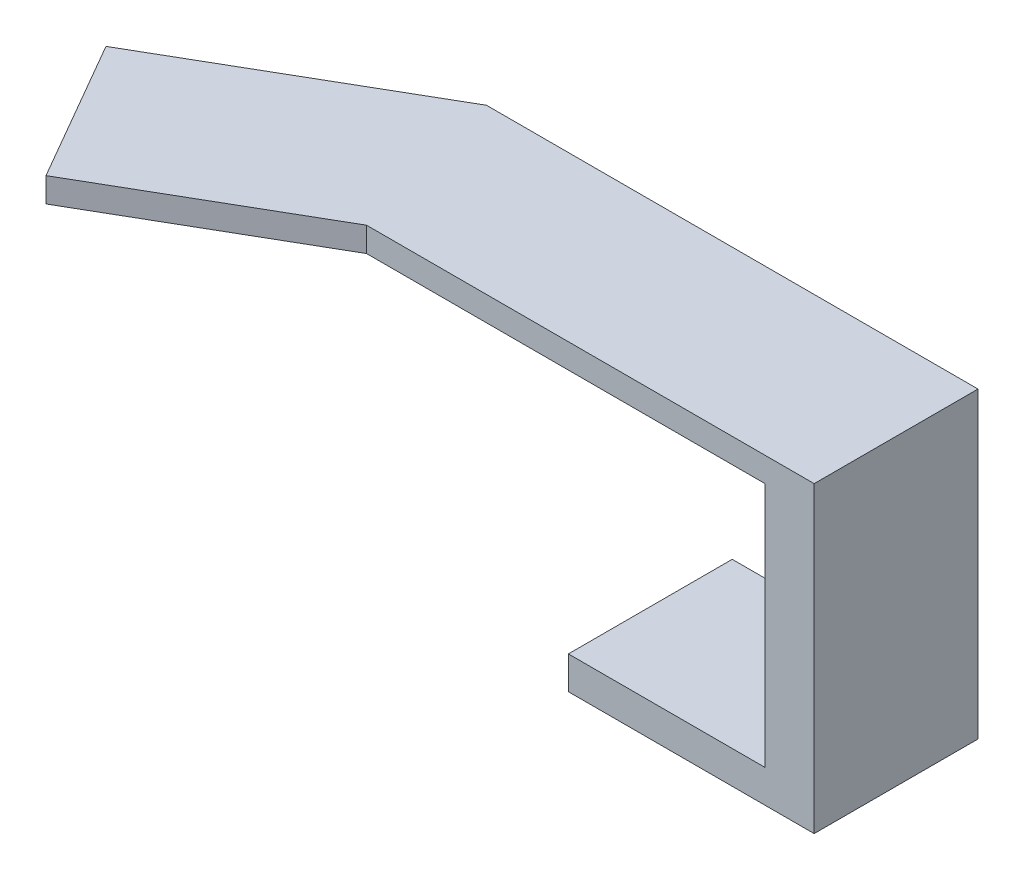
from build123d import *

# Parameters (mm, degrees)
BOSS_EXTRUDE1_DEPTH = 1.5
SKETCH2_W           = 3
SKETCH2_H           = 10
BOSS_EXTRUDE2_DEPTH = 17
SKETCH3_W           = 10
SKETCH3_H           = 2
BOSS_EXTRUDE3_DEPTH = 12


with BuildPart() as part:
    # Sketch1 → Boss-Extrude1 (new body)
    with BuildSketch(Plane(origin=(0, 0, 0), x_dir=(1, 0, 0), z_dir=(0, 1, 0))):
        Polygon((-10.606601718, 3.535533906), (-25.329033582, -4.964466094), (-20.329033582, -13.624720132), (-7.927109793, -6.464466094), (19.393398282, -6.464466094), (19.393398282, 3.535533906), align=None)
    extrude(amount=BOSS_EXTRUDE1_DEPTH)

    # Sketch2 → Boss-Extrude2 (add)
    with BuildSketch(Plane.XZ):
        with Locations((17.893398282, 1.464466094)):
            Rectangle(SKETCH2_W, SKETCH2_H)
    extrude(amount=BOSS_EXTRUDE2_DEPTH)

    # Sketch3 → Boss-Extrude3 (add)
    with BuildSketch(Plane.ZY.offset(-16.393398282)):
        with Locations((1.464466094, -16)):
            Rectangle(SKETCH3_W, SKETCH3_H)
    extrude(amount=BOSS_EXTRUDE3_DEPTH)


solid = part.part
